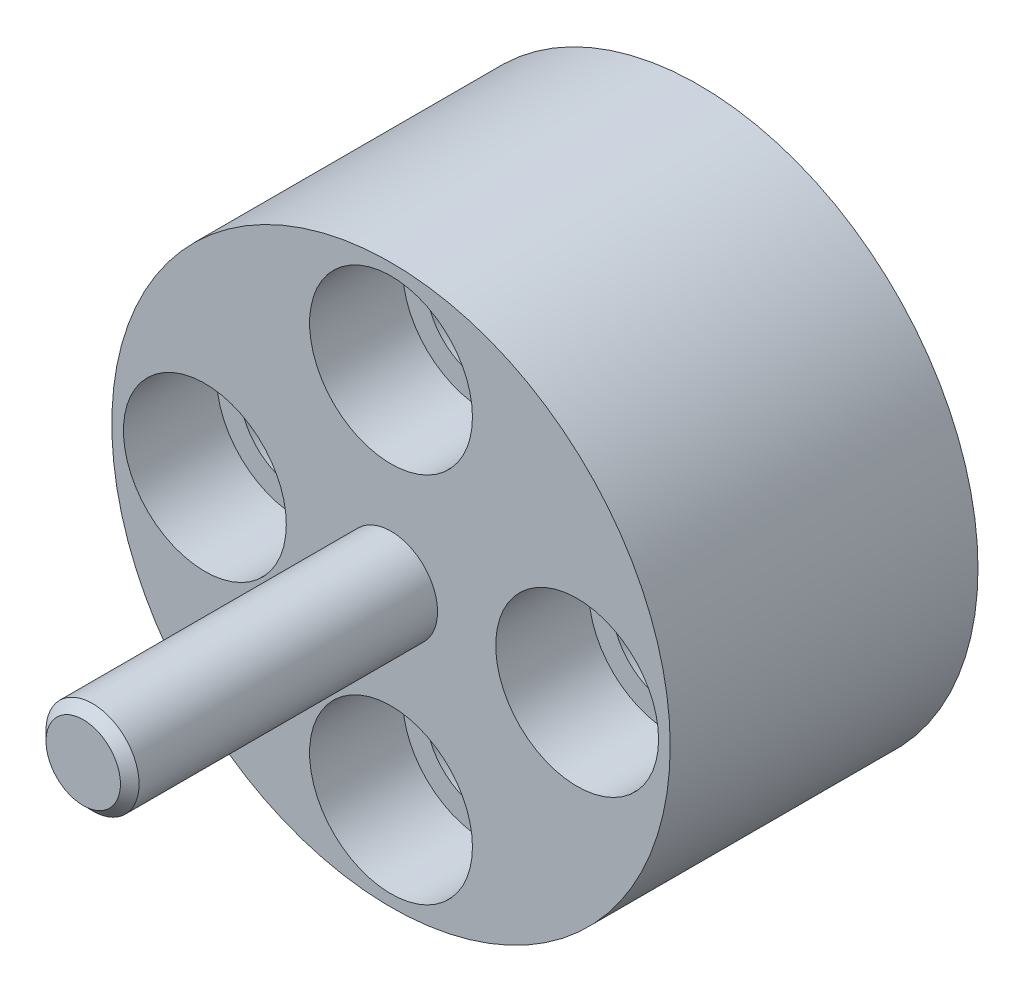
from build123d import *

# Parameters (mm, degrees)
SKETCH1_R                                        = 19.05
SKETCH1_R_2                                      = 5
SKETCH1_R_3                                      = 3.96875
BOSS_EXTRUDE1_DEPTH                              = 21
BOSS_EXTRUDE2_START                              = -14.142
SKETCH3_R                                        = 5
BOSS_EXTRUDE2_DEPTH                              = 14.142
SKETCH4_R                                        = 3.175
BOSS_EXTRUDE3_DEPTH                              = 21
CHAMFER1_SIZE                                    = 0.635
CBORE_FOR_1_4_SOCKET_HEAD_CAP_SCREW1_D           = 6.7564
CBORE_FOR_1_4_SOCKET_HEAD_CAP_SCREW1_CBORE_D     = 11.1125
CBORE_FOR_1_4_SOCKET_HEAD_CAP_SCREW1_CBORE_DEPTH = 6.35


with BuildPart() as part:
    # Sketch1 → Boss-Extrude1 (new body)
    with BuildSketch(Plane.XY):
        Circle(SKETCH1_R)
        Circle(SKETCH1_R_2, mode=Mode.SUBTRACT)
        with Locations((0, 12.7)):
            Circle(SKETCH1_R_3, mode=Mode.SUBTRACT)
        with Locations((12.7, 0)):
            Circle(SKETCH1_R_3, mode=Mode.SUBTRACT)
        with Locations((0, -12.7)):
            Circle(SKETCH1_R_3, mode=Mode.SUBTRACT)
        with Locations((-12.7, 0)):
            Circle(SKETCH1_R_3, mode=Mode.SUBTRACT)
    extrude(amount=BOSS_EXTRUDE1_DEPTH)

    # Sketch3 → Boss-Extrude2 (add)
    with BuildSketch(Plane(origin=(0, 0, 6.858), x_dir=(-1, 0, 0), z_dir=(0, 0, -1)).offset(BOSS_EXTRUDE2_START)):
        Circle(SKETCH3_R)
    extrude(amount=BOSS_EXTRUDE2_DEPTH)

    # Sketch4 → Boss-Extrude3 (add)
    with BuildSketch(Plane.XY.offset(21)):
        Circle(SKETCH4_R)
    extrude(amount=BOSS_EXTRUDE3_DEPTH)

    # Chamfer1
    chamfer1_edges = [part.edges().sort_by_distance(p)[0] for p in [
        (-3.175, 0, 42),
    ]]
    chamfer(chamfer1_edges, length=CHAMFER1_SIZE)

    # CBORE for 1/4 Socket Head Cap Screw1 (through all)
    with Locations(Plane.XY.offset(21)):
        with Locations((0, 12.7), (12.7, 0), (0, -12.7), (-12.7, 0)):
            CounterBoreHole(CBORE_FOR_1_4_SOCKET_HEAD_CAP_SCREW1_D / 2, CBORE_FOR_1_4_SOCKET_HEAD_CAP_SCREW1_CBORE_D / 2, CBORE_FOR_1_4_SOCKET_HEAD_CAP_SCREW1_CBORE_DEPTH)

    # Sketch7 → CBORE for 1/4 Socket Head Cap Screw2 (revolve, cut)
    with BuildSketch(Plane.YZ):
        Polygon((0, 0), (0, 2.055227343), (3.3782, 0.0254), (3.3782, 6.858), (5.55625, 6.858), (5.55625, 0), align=None)
    revolve(axis=Axis((0, 0, -6.35), (0, 0, 1)), mode=Mode.SUBTRACT)


solid = part.part
